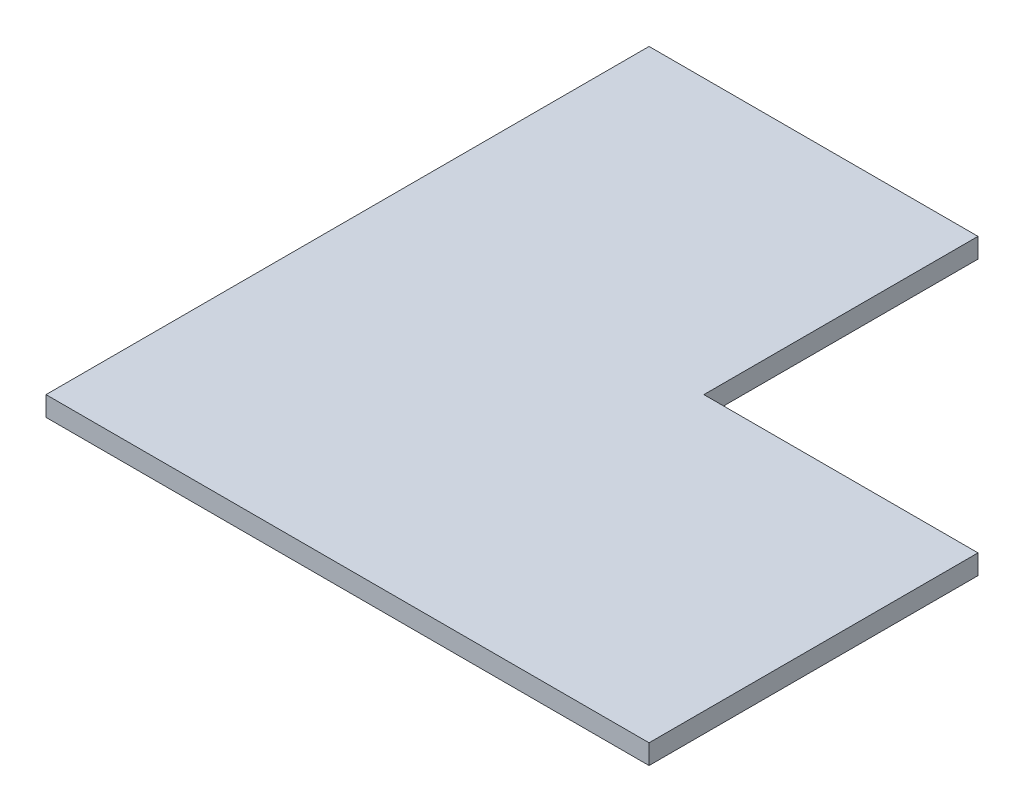
from build123d import *

# Parameters (mm, degrees)
EXTRUDE_1_DEPTH = 18


with BuildPart() as part:
    # Эскиз1 → Бобышка-Вытянуть1 (new body)
    with BuildSketch(Plane(origin=(0, 0, 0), x_dir=(1, 0, 0), z_dir=(0, 1, 0))):
        Polygon((0, 0), (0, 550), (300, 550), (300, 300), (550, 300), (550, 0), align=None)
    extrude(amount=EXTRUDE_1_DEPTH)


solid = part.part
